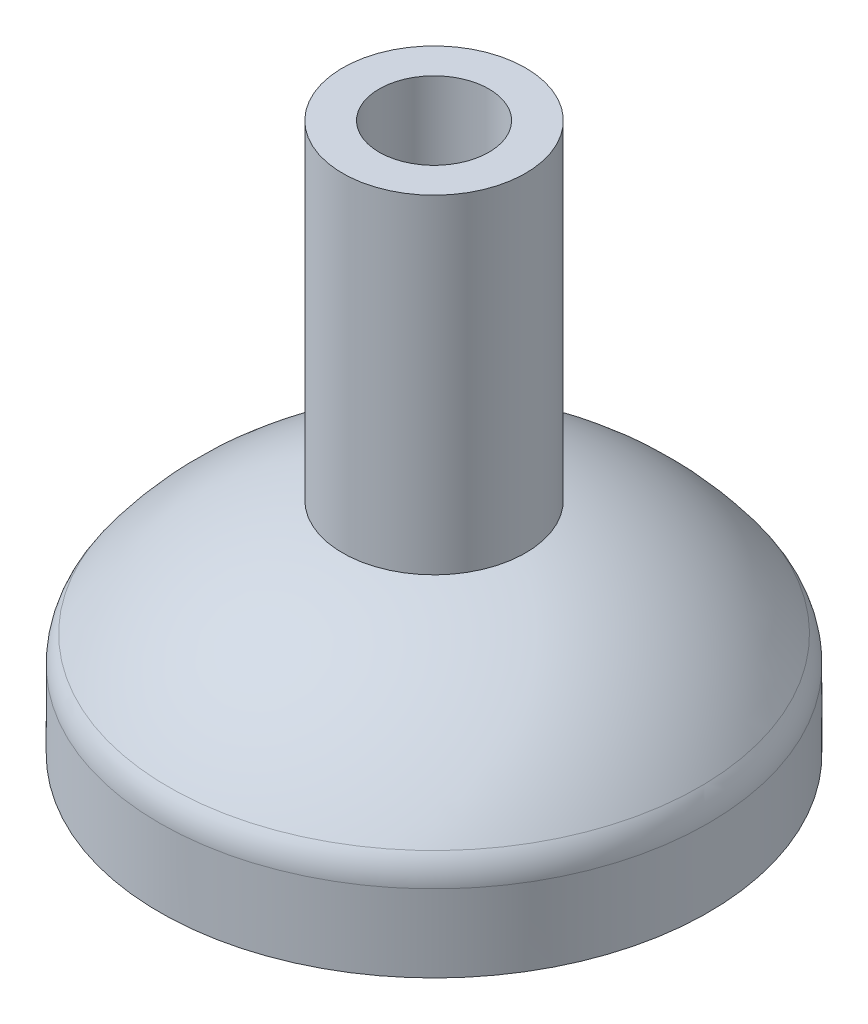
from build123d import *

# Parameters (mm, degrees)
SKIZZE4_R                       = 6
SCHNITT_LINEAR_AUSTRAGEN2_DEPTH = 51
VERRUNDUNG2_R                   = 5


with BuildPart() as part:
    # Skizze2 → Rotation2 (revolve)
    with BuildSketch(Plane.XY, mode=Mode.PRIVATE) as rotation2_sk:
        with BuildLine():
            Line((0, 14.040713887), (0, 50))
            Line((0, 50), (-10, 50))
            Line((-10, 50), (-10, 14.040713887))
            ThreePointArc((-10, 14.040713887), (-21.345292125, 8.936630056), (-30, 0))
            Line((-30, 0), (-30, -10))
            Line((-30, -10), (-25.817799793, -10))
            Line((-25.817799793, -10), (-25.817799793, -2.740292215))
            ThreePointArc((-25.817799793, -2.740292215), (-18.472392098, 4.844387952), (-8.843436705, 9.176316562))
            Line((-8.843436705, 9.176316562), (0, 9.176316562))
            Line((0, 9.176316562), (0, 14.040713887))
        make_face()
    revolve(rotation2_sk.sketch.rotate(Axis((0, 14.040713887, 0), (0, 1, 0)), 270), axis=Axis((0, 14.040713887, 0), (0, 1, 0)))  # turned: the seam where the file's is

    # Skizze4 → Schnitt-Linear austragen2 (cut, through all)
    with BuildSketch(Plane(origin=(0, 0, 0), x_dir=(1, 0, 0), z_dir=(0, 1, 0))):
        with Locations(Location((0, 0, 0), (0, 0, 270))):  # turned: the seam where the file's is
            Circle(SKIZZE4_R)
    extrude(amount=SCHNITT_LINEAR_AUSTRAGEN2_DEPTH, mode=Mode.SUBTRACT)

    # Verrundung2
    verrundung2_edges = [part.edges().sort_by_distance(p)[0] for p in [
        (0, 0, 30),
    ]]
    fillet(verrundung2_edges, radius=VERRUNDUNG2_R)


solid = part.part
